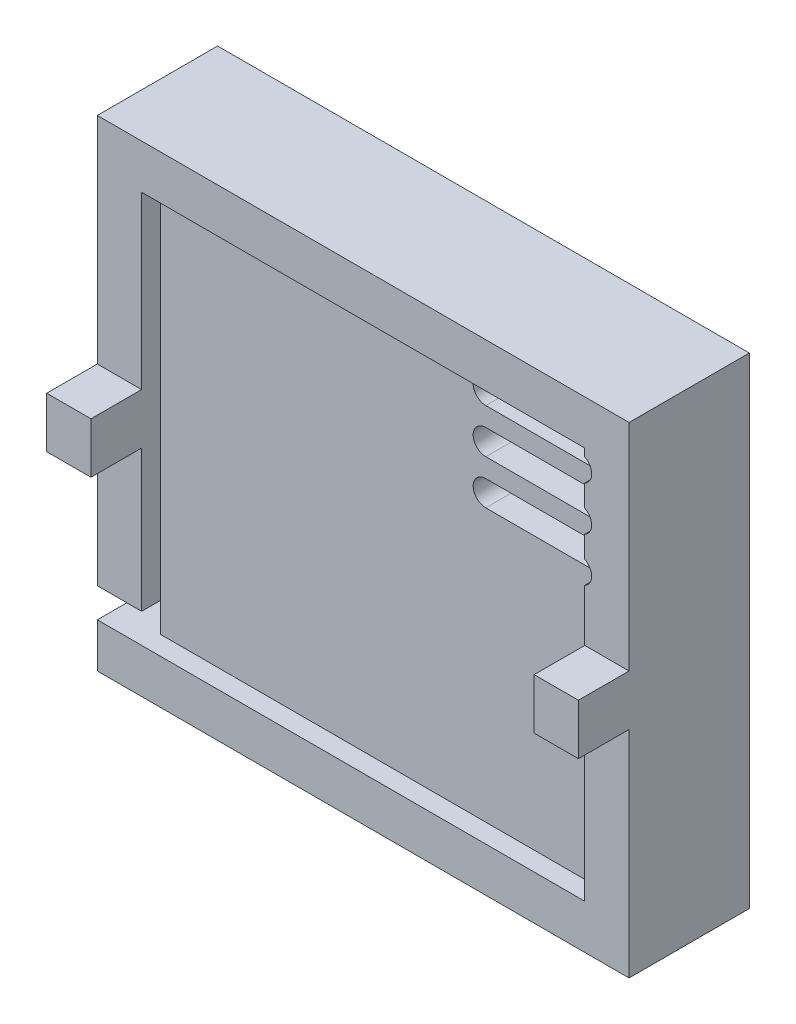
from build123d import *

# Parameters (mm, degrees)
SKETCH_1_W          = 42
SKETCH_1_H          = 38
EXTRUDE_1_DEPTH     = 3.5
EXTRUDE_2_DEPTH     = 4
SKETCH_3_W          = 35
SKETCH_3_H          = 31
CUT_EXTRUDE_1_DEPTH = 1.5
SKETCH_4_W          = 42
SKETCH_4_H          = 38
SKETCH_4_W_2        = 35
SKETCH_4_H_2        = 31
EXTRUDE_3_DEPTH     = 4
SKETCH_6_W          = 42
SKETCH_6_H          = 38
EXTRUDE_4_DEPTH     = 2
SKETCH_7_W          = 4
SKETCH_7_H          = 25
CUT_EXTRUDE_2_DEPTH = 3.5
SKETCH_8_W          = 3.5
SKETCH_8_H          = 2.331830178
CUT_EXTRUDE_3_DEPTH = 3.5
CUT_EXTRUDE_4_DEPTH = 10
SKETCH_10_W         = 1.5
SKETCH_10_H         = 31
EXTRUDE_5_DEPTH     = 5


with BuildPart() as part:
    # 草图1 → 凸台-拉伸1 (new body)
    with BuildSketch(Plane.XY):
        with Locations((21, 19)):
            Rectangle(SKETCH_1_W, SKETCH_1_H)
    extrude(amount=EXTRUDE_1_DEPTH)

    # 草图2 → 凸台-拉伸2 (add)
    with BuildSketch(Plane.XY.offset(3.5)):
        Polygon((0, 21), (0, 19), (0, 17), (3.5, 17), (3.5, 21), align=None)
        Polygon((42, 17), (42, 19), (42, 21), (38.5, 21), (38.5, 17), align=None)
    extrude(amount=EXTRUDE_2_DEPTH)

    # 草图3 → 切除-拉伸1 (cut)
    with BuildSketch(Plane.XY.offset(3.5)):
        with Locations((21, 19)):
            Rectangle(SKETCH_3_W, SKETCH_3_H)
    extrude(amount=-CUT_EXTRUDE_1_DEPTH, mode=Mode.SUBTRACT)

    # 草图4 → 凸台-拉伸3 (add)
    with BuildSketch(Plane(origin=(0, 0, 0), x_dir=(-1, 0, 0), z_dir=(0, 0, -1))):
        with Locations((-21, 19)):
            Rectangle(SKETCH_4_W, SKETCH_4_H)
        with Locations((-21, 19)):
            Rectangle(SKETCH_4_W_2, SKETCH_4_H_2, mode=Mode.SUBTRACT)
    extrude(amount=EXTRUDE_3_DEPTH)

    # 草图6 → 凸台-拉伸4 (add)
    with BuildSketch(Plane(origin=(0, 0, -4), x_dir=(-1, 0, 0), z_dir=(0, 0, -1))):
        with Locations((-21, 19)):
            Rectangle(SKETCH_6_W, SKETCH_6_H)
    extrude(amount=EXTRUDE_4_DEPTH)

    # 草图7 → 切除-拉伸2 (cut)
    with BuildSketch(Plane.ZY):
        with Locations((-2, 16)):
            Rectangle(SKETCH_7_W, SKETCH_7_H)
    extrude(amount=-CUT_EXTRUDE_2_DEPTH, mode=Mode.SUBTRACT)

    # 草图8 → 切除-拉伸3 (cut)
    with BuildSketch(Plane.ZY):
        with Locations((1.75, 4.665915089)):
            Rectangle(SKETCH_8_W, SKETCH_8_H)
    extrude(amount=-CUT_EXTRUDE_3_DEPTH, mode=Mode.SUBTRACT)

    # 草图9 → 切除-拉伸4 (cut)
    with BuildSketch(Plane(origin=(0, 0, -6), x_dir=(-1, 0, 0), z_dir=(0, 0, -1))):
        with BuildLine():
            Line((-38.044699478, 27), (-29.186779496, 27))
            ThreePointArc((-29.186779496, 27), (-28.186779496, 26), (-29.186779496, 25))
            Line((-29.186779496, 25), (-38.044699478, 25))
            ThreePointArc((-38.044699478, 25), (-39.044699478, 26), (-38.044699478, 27))
        make_face()
        with BuildLine():
            Line((-38.044699478, 30.5), (-29.186779496, 30.5))
            ThreePointArc((-29.186779496, 30.5), (-28.186779496, 29.5), (-29.186779496, 28.5))
            Line((-29.186779496, 28.5), (-38.044699478, 28.5))
            ThreePointArc((-38.044699478, 28.5), (-39.044699478, 29.5), (-38.044699478, 30.5))
        make_face()
        with BuildLine():
            Line((-38.044699478, 34), (-29.186779496, 34))
            ThreePointArc((-29.186779496, 34), (-28.186779496, 33), (-29.186779496, 32))
            Line((-29.186779496, 32), (-38.044699478, 32))
            ThreePointArc((-38.044699478, 32), (-39.044699478, 33), (-38.044699478, 34))
        make_face()
    extrude(amount=-CUT_EXTRUDE_4_DEPTH, mode=Mode.SUBTRACT)

    # 草图10 → 凸台-拉伸5 (add)
    with BuildSketch(Plane(origin=(0, 0, 0), x_dir=(-1, 0, 0), z_dir=(0, 0, -1))):
        with Locations((-27.23390418, 19)):
            Rectangle(SKETCH_10_W, SKETCH_10_H)
    extrude(amount=EXTRUDE_5_DEPTH)


solid = part.part
